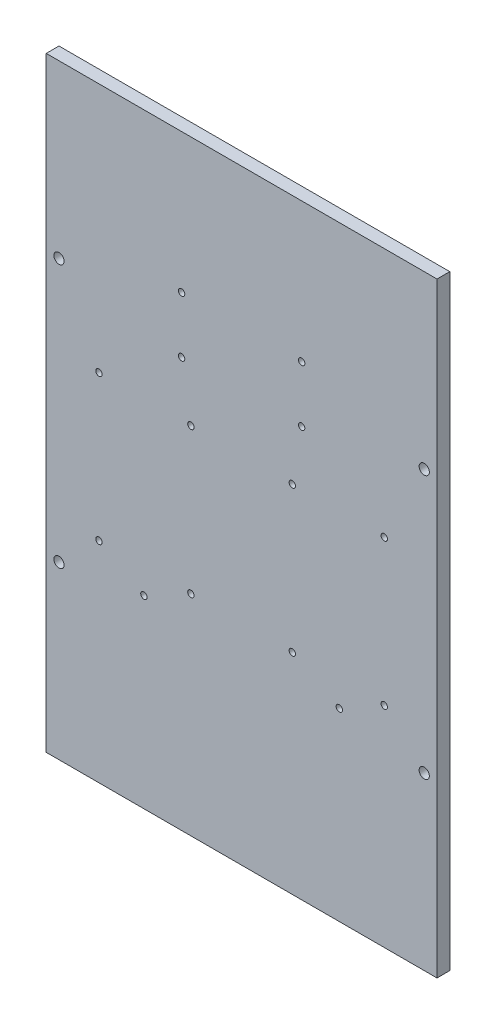
from build123d import *

# Parameters (mm, degrees)
CROQUIS1_W              = 153
CROQUIS1_H              = 237
SALIENTE_EXTRUIR1_DEPTH = 5
CROQUIS2_R              = 2
CORTAR_EXTRUIR1_DEPTH   = 5
CROQUIS3_R              = 1.25
CORTAR_EXTRUIR2_DEPTH   = 10
CROQUIS4_R              = 1.25
CORTAR_EXTRUIR3_DEPTH   = 10


with BuildPart() as part:
    # Croquis1 → Saliente-Extruir1 (new body)
    with BuildSketch(Plane.XY):
        with Locations((76.5, 118.5)):
            Rectangle(CROQUIS1_W, CROQUIS1_H)
    extrude(amount=SALIENTE_EXTRUIR1_DEPTH)

    # Croquis2 → Cortar-Extruir1 (cut)
    with BuildSketch(Plane.XY.offset(5)):
        with Locations((5, 170)):
            Circle(CROQUIS2_R)
        with Locations((148, 170)):
            Circle(CROQUIS2_R)
        with Locations((5, 67)):
            Circle(CROQUIS2_R)
        with Locations((148, 67)):
            Circle(CROQUIS2_R)
    extrude(amount=-CORTAR_EXTRUIR1_DEPTH, mode=Mode.SUBTRACT)

    # Croquis3 → Cortar-Extruir2 (cut)
    with BuildSketch(Plane.XY.offset(5)):
        with Locations((20.649331187, 139.09012035)):
            Circle(CROQUIS3_R)
        with Locations((56.649331187, 139.09012035)):
            Circle(CROQUIS3_R)
        with Locations((56.649331187, 82.09012035)):
            Circle(CROQUIS3_R)
        with Locations((20.649331187, 82.09012035)):
            Circle(CROQUIS3_R)
        with Locations((114.75, 72.302318418)):
            Circle(CROQUIS3_R)
        with Locations((38.25, 72.302318418)):
            Circle(CROQUIS3_R)
        with Locations((132.350668813, 82.09012035)):
            Circle(CROQUIS3_R)
        with Locations((96.350668813, 82.09012035)):
            Circle(CROQUIS3_R)
        with Locations((96.350668813, 139.09012035)):
            Circle(CROQUIS3_R)
        with Locations((132.350668813, 139.09012035)):
            Circle(CROQUIS3_R)
    extrude(amount=-CORTAR_EXTRUIR2_DEPTH, mode=Mode.SUBTRACT)

    # Croquis4 → Cortar-Extruir3 (cut)
    with BuildSketch(Plane.XY.offset(5)):
        with Locations((53, 182.458833487)):
            Circle(CROQUIS4_R)
        with Locations((53, 160.458833487)):
            Circle(CROQUIS4_R)
        with Locations((100, 182.458833487)):
            Circle(CROQUIS4_R)
        with Locations((100, 160.458833487)):
            Circle(CROQUIS4_R)
    extrude(amount=-CORTAR_EXTRUIR3_DEPTH, mode=Mode.SUBTRACT)


solid = part.part
